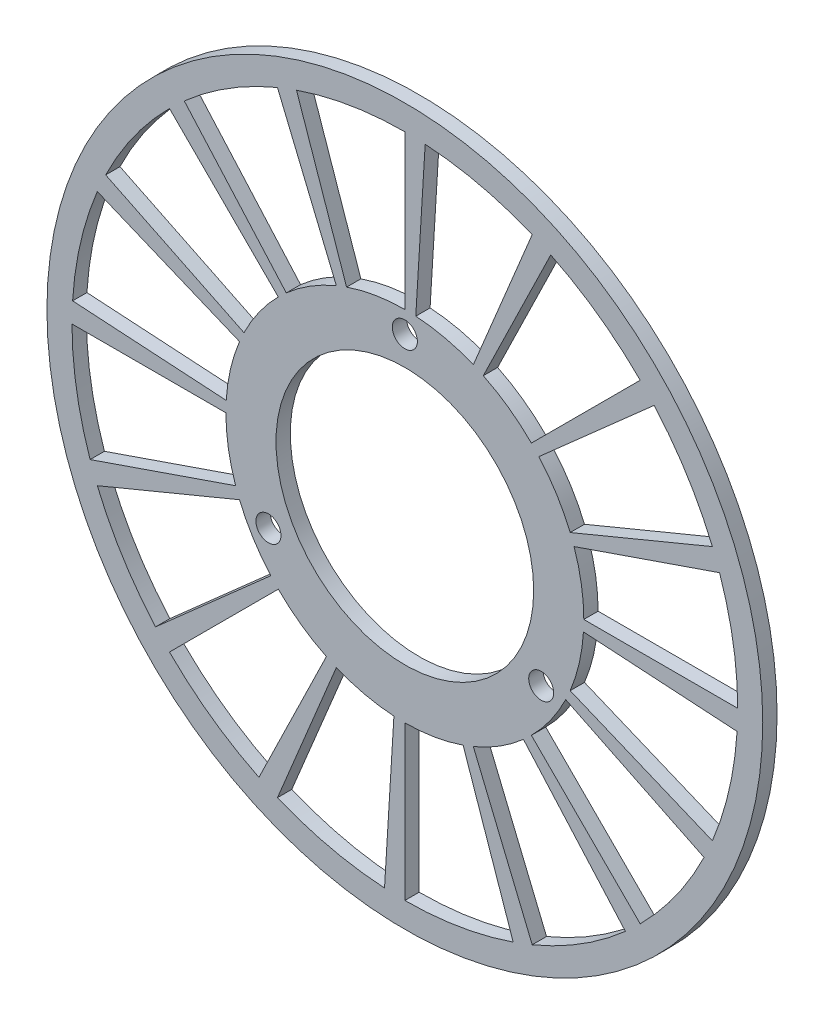
from build123d import *

# Parameters (mm, degrees)
SKETCH1_R           = 50
SKETCH1_R_2         = 18
SKETCH1_R_3         = 1.75
BOSS_EXTRUDE1_DEPTH = 2


with BuildPart() as part:
    # Sketch1 → Boss-Extrude1 (new body)
    with BuildSketch(Plane.XY):
        Circle(SKETCH1_R)
        Circle(SKETCH1_R_2, mode=Mode.SUBTRACT)
        with Locations((0, 22)):
            Circle(SKETCH1_R_3, mode=Mode.SUBTRACT)
        with Locations((19.052558883, -11)):
            Circle(SKETCH1_R_3, mode=Mode.SUBTRACT)
        with Locations((-19.052558883, -11)):
            Circle(SKETCH1_R_3, mode=Mode.SUBTRACT)
        with BuildLine():
            Line((25, 0), (46.5, 0))
            ThreePointArc((46.5, 0), (45.862280471, 7.674713673), (43.966613765, 15.138919182))
            Line((43.966613765, 15.138919182), (23.63796439, 8.139203861))
            ThreePointArc((23.63796439, 8.139203861), (24.657140038, 4.126190147), (25, 0))
        make_face(mode=Mode.SUBTRACT)
        with BuildLine():
            Line((23.096988313, -9.567085809), (42.960398262, -17.794779605))
            ThreePointArc((42.960398262, -17.794779605), (45.308208013, -10.460224027), (46.413268127, -2.838757088))
            Line((46.413268127, -2.838757088), (24.953369961, -1.526213488))
            ThreePointArc((24.953369961, -1.526213488), (24.35925162, -5.623776359), (23.096988313, -9.567085809))
        make_face(mode=Mode.SUBTRACT)
        with BuildLine():
            Line((17.67766953, -17.67766953), (32.880465325, -32.880465325))
            ThreePointArc((32.880465325, -32.880465325), (37.856371604, -27.002687441), (41.793923153, -20.384258326))
            Line((41.793923153, -20.384258326), (22.469851157, -10.95927867))
            ThreePointArc((22.469851157, -10.95927867), (20.352887959, -14.517573893), (17.67766953, -17.67766953))
        make_face(mode=Mode.SUBTRACT)
        with BuildLine():
            Line((9.567085809, -23.096988313), (17.794779605, -42.960398262))
            ThreePointArc((17.794779605, -42.960398262), (24.641245787, -39.434236471), (30.811832242, -34.826441017))
            Line((30.811832242, -34.826441017), (16.565501205, -18.72389302))
            ThreePointArc((16.565501205, -18.72389302), (13.247981606, -21.201202404), (9.567085809, -23.096988313))
        make_face(mode=Mode.SUBTRACT)
        with BuildLine():
            Line((0, -25), (0, -46.5))
            ThreePointArc((0, -46.5), (7.674713673, -45.862280471), (15.138919182, -43.966613765))
            Line((15.138919182, -43.966613765), (8.139203861, -23.63796439))
            ThreePointArc((8.139203861, -23.63796439), (4.126190147, -24.657140038), (0, -25))
        make_face(mode=Mode.SUBTRACT)
        with BuildLine():
            Line((-9.567085809, -23.096988313), (-17.794779605, -42.960398262))
            ThreePointArc((-17.794779605, -42.960398262), (-10.460224027, -45.308208013), (-2.838757088, -46.413268127))
            Line((-2.838757088, -46.413268127), (-1.526213488, -24.953369961))
            ThreePointArc((-1.526213488, -24.953369961), (-5.623776359, -24.35925162), (-9.567085809, -23.096988313))
        make_face(mode=Mode.SUBTRACT)
        with BuildLine():
            Line((-17.67766953, -17.67766953), (-32.880465325, -32.880465325))
            ThreePointArc((-32.880465325, -32.880465325), (-27.002687441, -37.856371604), (-20.384258326, -41.793923153))
            Line((-20.384258326, -41.793923153), (-10.95927867, -22.469851157))
            ThreePointArc((-10.95927867, -22.469851157), (-14.517573893, -20.352887959), (-17.67766953, -17.67766953))
        make_face(mode=Mode.SUBTRACT)
        with BuildLine():
            Line((-23.096988313, -9.567085809), (-42.960398262, -17.794779605))
            ThreePointArc((-42.960398262, -17.794779605), (-39.434236471, -24.641245787), (-34.826441017, -30.811832242))
            Line((-34.826441017, -30.811832242), (-18.72389302, -16.565501205))
            ThreePointArc((-18.72389302, -16.565501205), (-21.201202404, -13.247981606), (-23.096988313, -9.567085809))
        make_face(mode=Mode.SUBTRACT)
        with BuildLine():
            Line((-25, 0), (-46.5, 0))
            ThreePointArc((-46.5, 0), (-45.862280471, -7.674713673), (-43.966613765, -15.138919182))
            Line((-43.966613765, -15.138919182), (-23.63796439, -8.139203861))
            ThreePointArc((-23.63796439, -8.139203861), (-24.657140038, -4.126190147), (-25, 0))
        make_face(mode=Mode.SUBTRACT)
        with BuildLine():
            Line((-23.096988313, 9.567085809), (-42.960398262, 17.794779605))
            ThreePointArc((-42.960398262, 17.794779605), (-45.308208013, 10.460224027), (-46.413268127, 2.838757088))
            Line((-46.413268127, 2.838757088), (-24.953369961, 1.526213488))
            ThreePointArc((-24.953369961, 1.526213488), (-24.35925162, 5.623776359), (-23.096988313, 9.567085809))
        make_face(mode=Mode.SUBTRACT)
        with BuildLine():
            Line((-17.67766953, 17.67766953), (-32.880465325, 32.880465325))
            ThreePointArc((-32.880465325, 32.880465325), (-37.856371604, 27.002687441), (-41.793923153, 20.384258326))
            Line((-41.793923153, 20.384258326), (-22.469851157, 10.95927867))
            ThreePointArc((-22.469851157, 10.95927867), (-20.352887959, 14.517573893), (-17.67766953, 17.67766953))
        make_face(mode=Mode.SUBTRACT)
        with BuildLine():
            Line((-9.567085809, 23.096988313), (-17.794779605, 42.960398262))
            ThreePointArc((-17.794779605, 42.960398262), (-24.641245787, 39.434236471), (-30.811832242, 34.826441017))
            Line((-30.811832242, 34.826441017), (-16.565501205, 18.72389302))
            ThreePointArc((-16.565501205, 18.72389302), (-13.247981606, 21.201202404), (-9.567085809, 23.096988313))
        make_face(mode=Mode.SUBTRACT)
        with BuildLine():
            Line((0, 25), (0, 46.5))
            ThreePointArc((0, 46.5), (-7.674713673, 45.862280471), (-15.138919182, 43.966613765))
            Line((-15.138919182, 43.966613765), (-8.139203861, 23.63796439))
            ThreePointArc((-8.139203861, 23.63796439), (-4.126190147, 24.657140038), (0, 25))
        make_face(mode=Mode.SUBTRACT)
        with BuildLine():
            Line((9.567085809, 23.096988313), (17.794779605, 42.960398262))
            ThreePointArc((17.794779605, 42.960398262), (10.460224027, 45.308208013), (2.838757088, 46.413268127))
            Line((2.838757088, 46.413268127), (1.526213488, 24.953369961))
            ThreePointArc((1.526213488, 24.953369961), (5.623776359, 24.35925162), (9.567085809, 23.096988313))
        make_face(mode=Mode.SUBTRACT)
        with BuildLine():
            Line((17.67766953, 17.67766953), (32.880465325, 32.880465325))
            ThreePointArc((32.880465325, 32.880465325), (27.002687441, 37.856371604), (20.384258326, 41.793923153))
            Line((20.384258326, 41.793923153), (10.95927867, 22.469851157))
            ThreePointArc((10.95927867, 22.469851157), (14.517573893, 20.352887959), (17.67766953, 17.67766953))
        make_face(mode=Mode.SUBTRACT)
        with BuildLine():
            Line((23.096988313, 9.567085809), (42.960398262, 17.794779605))
            ThreePointArc((42.960398262, 17.794779605), (39.434236471, 24.641245787), (34.826441017, 30.811832242))
            Line((34.826441017, 30.811832242), (18.72389302, 16.565501205))
            ThreePointArc((18.72389302, 16.565501205), (21.201202404, 13.247981606), (23.096988313, 9.567085809))
        make_face(mode=Mode.SUBTRACT)
    extrude(amount=BOSS_EXTRUDE1_DEPTH)


solid = part.part
